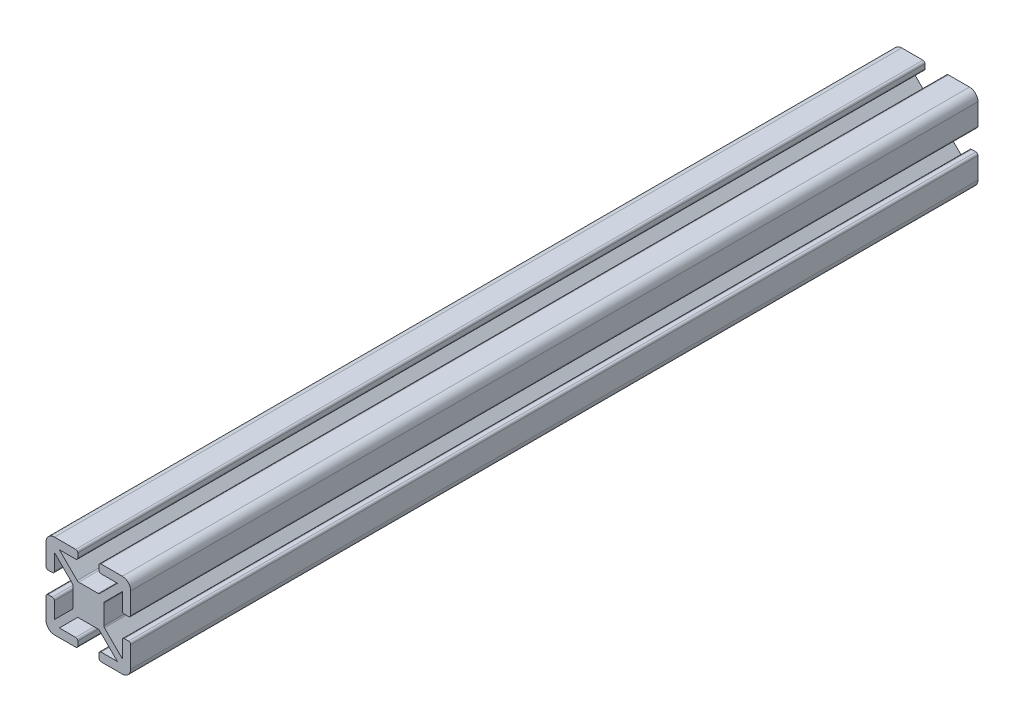
from build123d import *

# Parameters (mm, degrees)
AUFSATZ_LINEAR_AUSTRAGEN1_DEPTH = 200
VERRUNDUNG1_R                   = 2
VERRUNDUNG2_R                   = 0.5


with BuildPart() as part:
    # Skizze1 → Aufsatz-Linear austragen1 (new body)
    with BuildSketch(Plane.XY):
        Polygon((-10, 2.5), (-8, 2.5), (-8, 6.85), (-3.65, 2.5), (-3.65, -2.5), (-8, -6.85), (-8, -2.5), (-10, -2.5), (-10, -10), (-2.5, -10), (-2.5, -8), (-6.85, -8), (-2.5, -3.65), (2.5, -3.65), (6.85, -8), (2.5, -8), (2.5, -10), (10, -10), (10, -2.5), (8, -2.5), (8, -6.85), (3.65, -2.5), (3.65, 2.5), (8, 6.85), (8, 2.5), (10, 2.5), (10, 10), (2.5, 10), (2.5, 8), (6.85, 8), (2.5, 3.65), (-2.5, 3.65), (-6.85, 8), (-2.5, 8), (-2.5, 10), (-10, 10), align=None)
    extrude(amount=AUFSATZ_LINEAR_AUSTRAGEN1_DEPTH)

    # Verrundung1
    verrundung1_edges = [part.edges().sort_by_distance(p)[0] for p in [
        (-10, 10, 100),
        (-10, -10, 100),
        (10, -10, 100),
        (10, 10, 100),
    ]]
    fillet(verrundung1_edges, radius=VERRUNDUNG1_R)

    # Verrundung2
    verrundung2_edges = [part.edges().sort_by_distance(p)[0] for p in [
        (-2.5, 10, 100),
        (-10, 2.5, 100),
        (-8, 2.5, 100),
        (-3.65, 2.5, 100),
        (-3.65, -2.5, 100),
        (-8, -2.5, 100),
        (-10, -2.5, 100),
        (-2.5, -10, 100),
        (-2.5, -8, 100),
        (-2.5, -3.65, 100),
        (2.5, -3.65, 100),
        (2.5, -8, 100),
        (2.5, -10, 100),
        (10, -2.5, 100),
        (8, -2.5, 100),
        (3.65, -2.5, 100),
        (3.65, 2.5, 100),
        (8, 2.5, 100),
        (10, 2.5, 100),
        (2.5, 10, 100),
        (2.5, 8, 100),
        (2.5, 3.65, 100),
        (-2.5, 3.65, 100),
        (-2.5, 8, 100),
    ]]
    fillet(verrundung2_edges, radius=VERRUNDUNG2_R)


solid = part.part
